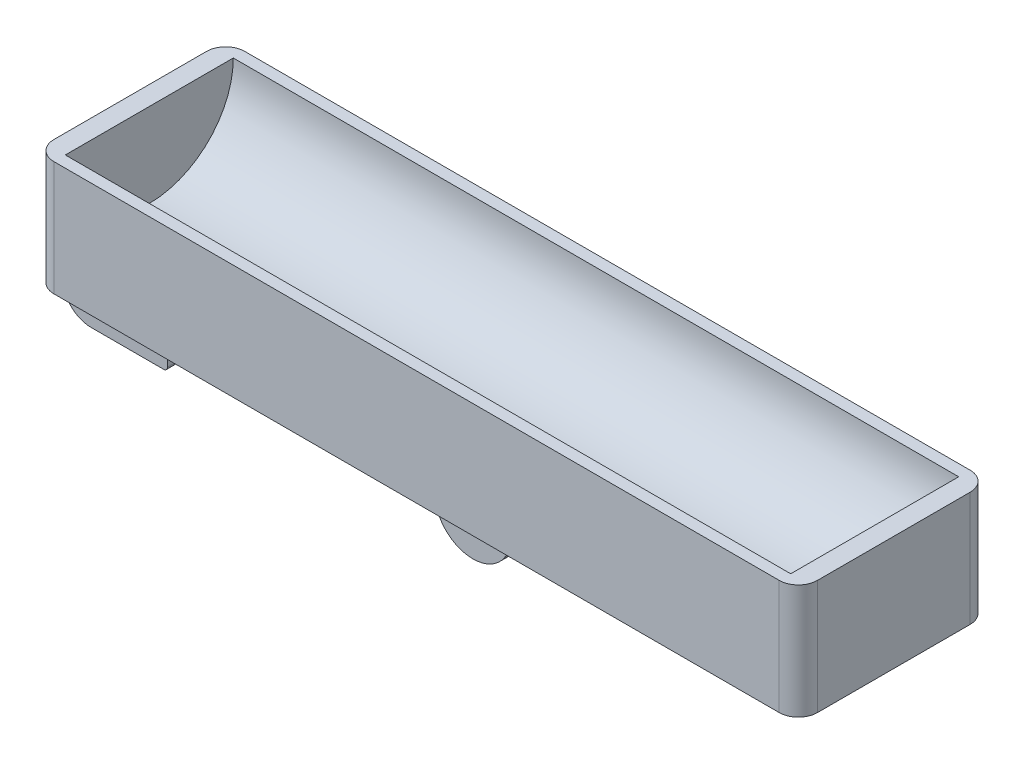
from build123d import *

# Parameters (mm, degrees)
SKETCH2_W           = 50
SKETCH2_H           = 30
BOSS_EXTRUDE2_DEPTH = 100
CUT_EXTRUDE1_DEPTH  = 95
SKETCH4_W           = 20
SKETCH4_H           = 5
BOSS_EXTRUDE3_DEPTH = 10
BOSS_EXTRUDE4_DEPTH = 5
SKETCH6_R           = 2.55
CUT_EXTRUDE2_DEPTH  = 5
SKETCH9_R           = 2.55
BOSS_EXTRUDE6_DEPTH = 5
FILLET1_R           = 5
FILLET3_R           = 1


with BuildPart() as part:
    # Sketch2 → Boss-Extrude2 (new body)
    with BuildSketch(Plane(origin=(0, 0, 0), x_dir=(0, 0, -1), z_dir=(1, 0, 0))):
        Rectangle(SKETCH2_W, SKETCH2_H)
    boss_extrude2 = extrude(amount=BOSS_EXTRUDE2_DEPTH)

    # Sketch3 → Cut-Extrude1 (cut)
    with BuildSketch(Plane.ZY):
        with BuildLine():
            Line((22, 15), (-22, 15))
            ThreePointArc((-22, 15), (0, -7), (22, 15))
        make_face()
    cut_extrude1 = extrude(amount=-CUT_EXTRUDE1_DEPTH, mode=Mode.SUBTRACT)

    # Mirror7: Boss-Extrude2, Cut-Extrude1 across plane
    add(boss_extrude2.mirror(Plane(origin=(0, 0, 0), x_dir=(0, 0, 1), z_dir=(1, 0, 0))))
    add(cut_extrude1.mirror(Plane(origin=(0, 0, 0), x_dir=(0, 0, 1), z_dir=(1, 0, 0))), mode=Mode.SUBTRACT)

    # Sketch4 → Boss-Extrude3 (add)
    with BuildSketch(Plane.XZ.offset(15)):
        with Locations((0, -7.75)):
            Rectangle(SKETCH4_W, SKETCH4_H)
    boss_extrude3 = extrude(amount=BOSS_EXTRUDE3_DEPTH)

    # Sketch5 → Boss-Extrude4 (add)
    with BuildSketch(Plane(origin=(0, 0, -10.25), x_dir=(-1, 0, 0), z_dir=(0, 0, -1))):
        with BuildLine():
            Line((-10, -25), (10, -25))
            ThreePointArc((10, -25), (0, -35), (-10, -25))
        make_face()
    boss_extrude4 = extrude(amount=-BOSS_EXTRUDE4_DEPTH)

    # Sketch6 → Cut-Extrude2 (cut)
    with BuildSketch(Plane(origin=(0, 0, -10.25), x_dir=(-1, 0, 0), z_dir=(0, 0, -1))):
        with Locations((0, -25)):
            Circle(SKETCH6_R)
    cut_extrude2 = extrude(amount=-CUT_EXTRUDE2_DEPTH, mode=Mode.SUBTRACT)

    # Mirror12: Boss-Extrude3, Boss-Extrude4, Cut-Extrude2 across plane
    add(boss_extrude3.mirror(Plane.XY))
    add(boss_extrude4.mirror(Plane.XY))
    add(cut_extrude2.mirror(Plane.XY), mode=Mode.SUBTRACT)

    # Sketch9 → Boss-Extrude6 (add)
    with BuildSketch(Plane(origin=(0, 0, -10.25), x_dir=(-1, 0, 0), z_dir=(0, 0, -1))):
        with BuildLine():
            Line((80, -15), (95, -15))
            Line((95, -15), (95, -17.5))
            Line((95, -17.5), (100, -17.5))
            ThreePointArc((100, -17.5), (107.5, -25), (100, -32.5))
            Line((100, -32.5), (80, -32.5))
            Line((80, -32.5), (80, -15))
        make_face()
        with Locations((100, -25)):
            Circle(SKETCH9_R, mode=Mode.SUBTRACT)
    boss_extrude6 = extrude(amount=-BOSS_EXTRUDE6_DEPTH)

    # Mirror13: Boss-Extrude6 across plane
    add(boss_extrude6.mirror(Plane.XY))

    # Fillet1
    fillet1_edges = [part.edges().sort_by_distance(p)[0] for p in [
        (100, 0, 25),
        (-100, 0, -25),
        (-100, 0, 25),
        (100, 0, -25),
    ]]
    fillet(fillet1_edges, radius=FILLET1_R)

    # Fillet3
    fillet3_edges = [part.edges().sort_by_distance(p)[0] for p in [
        (-87.5, -15, -10.25),
        (-87.5, -15, 5.25),
        (-87.5, -15, 10.25),
        (-95, -15, 7.75),
        (-80, -15, 7.75),
        (-80, -32.5, 7.75),
        (10, -15, -7.75),
        (0, -15, -5.25),
        (-10, -15, -7.75),
        (0, -15, -10.25),
        (10, -15, 7.75),
        (0, -15, 5.25),
        (-10, -15, 7.75),
        (0, -15, 10.25),
        (-95, -15, -7.75),
        (-80, -32.5, -7.75),
        (-87.5, -15, -5.25),
        (-80, -15, -7.75),
    ]]
    fillet(fillet3_edges, radius=FILLET3_R)


solid = part.part
